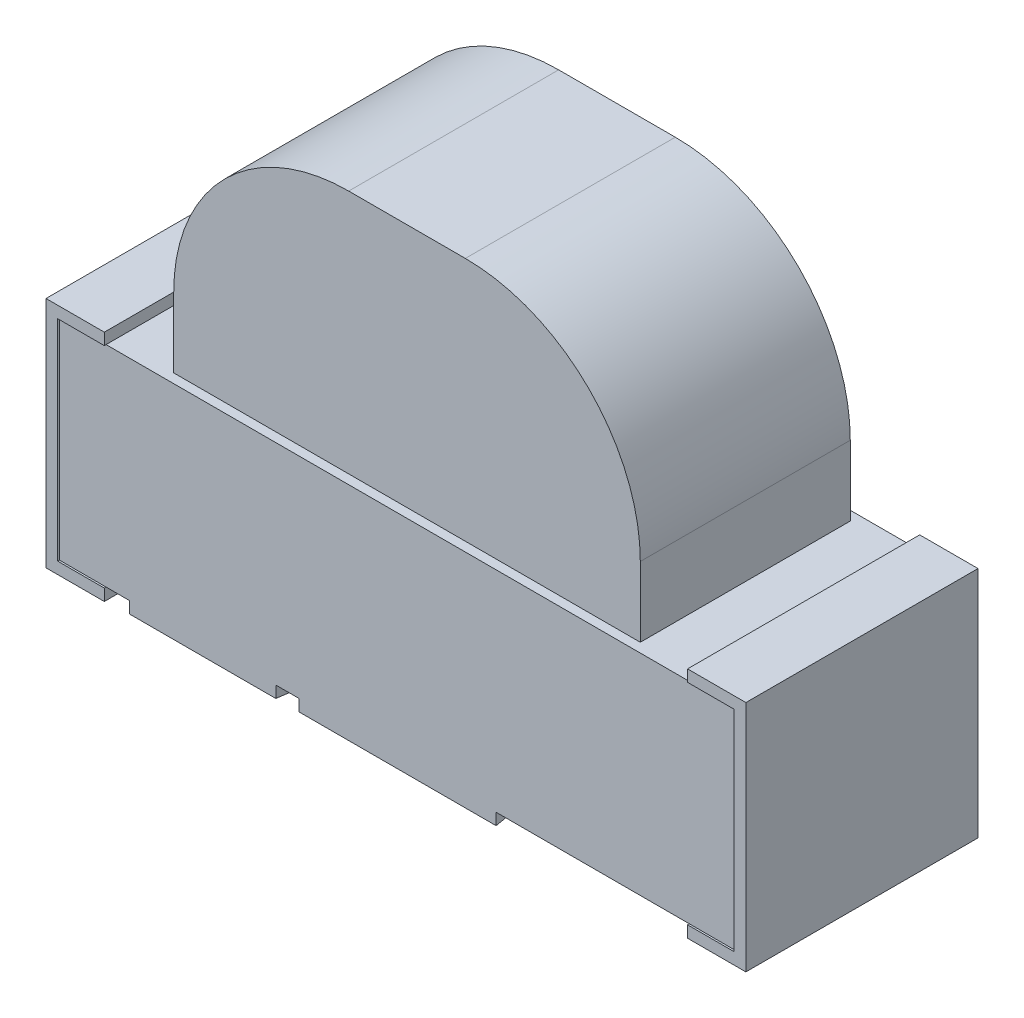
from build123d import *

# Parameters (mm, degrees)
SKIZZE1_W                       = 2.9
SKIZZE1_H                       = 0.98
LINEAR_AUSTRAGEN1_DEPTH         = 0.9
LINEAR_AUSTRAGEN2_DEPTH         = 0.45
SKIZZE5_W                       = 3
SKIZZE5_H                       = 1.08
SKIZZE5_W_2                     = 2.9
SKIZZE5_H_2                     = 0.98
LINEAR_AUSTRAGEN6_DEPTH         = 0.9
SKIZZE6_W                       = 0.25
SKIZZE6_H                       = 1.08
LINEAR_AUSTRAGEN7_DEPTH         = 0.05
SKIZZE7_W                       = 0.25
SKIZZE7_H                       = 1.08
LINEAR_AUSTRAGEN8_DEPTH         = 0.05
LINEAR_AUSTRAGEN9_DEPTH         = 0.05
SCHNITT_LINEAR_AUSTRAGEN2_DEPTH = 0.05
SKIZZE10_W                      = 3
SKIZZE10_H                      = 1
SCHNITT_LINEAR_AUSTRAGEN3_DEPTH = 0.0425


with BuildPart() as part:
    # Skizze1 → Linear austragen1 (new body)
    with BuildSketch(Plane(origin=(0, 0, 0), x_dir=(1, 0, 0), z_dir=(0, 1, 0))):
        Rectangle(SKIZZE1_W, SKIZZE1_H)
    extrude(amount=LINEAR_AUSTRAGEN1_DEPTH)



with BuildPart() as body_2:
    # Skizze2 → Linear austragen2 (new body, symmetric)
    with BuildSketch(Plane.XY):
        with BuildLine():
            Line((-1, 0.9), (1, 0.9))
            Line((1, 0.9), (1, 1.2))
            ThreePointArc((1, 1.2), (0.780330086, 1.730330086), (0.25, 1.95))
            Line((0.25, 1.95), (-0.25, 1.95))
            ThreePointArc((-0.25, 1.95), (-0.780330086, 1.730330086), (-1, 1.2))
            Line((-1, 1.2), (-1, 0.9))
        make_face()
    extrude(amount=LINEAR_AUSTRAGEN2_DEPTH, both=True)


with BuildPart() as body_3:
    # Skizze5 → Linear austragen6 (new body)
    with BuildSketch(Plane(origin=(0, 0.9, 0), x_dir=(1, 0, 0), z_dir=(0, 1, 0))):
        Rectangle(SKIZZE5_W, SKIZZE5_H)
        Rectangle(SKIZZE5_W_2, SKIZZE5_H_2, mode=Mode.SUBTRACT)
    extrude(amount=-LINEAR_AUSTRAGEN6_DEPTH)


with BuildPart() as part_1:
    add(part.part)

    add(body_3.part)  # Linear austragen7 merges body 3
    # Skizze6 → Linear austragen7 (add)
    with BuildSketch(Plane(origin=(0, 0.9, 0), x_dir=(1, 0, 0), z_dir=(0, 1, 0))):
        with Locations((1.375, 0)):
            Rectangle(SKIZZE6_W, SKIZZE6_H)
        with Locations((-1.375, 0)):
            Rectangle(SKIZZE6_W, SKIZZE6_H)
    extrude(amount=LINEAR_AUSTRAGEN7_DEPTH)

    # Skizze7 → Linear austragen8 (add)
    with BuildSketch(Plane.XZ):
        with Locations((1.375, 0)):
            Rectangle(SKIZZE7_W, SKIZZE7_H)
        with Locations((-1.375, 0)):
            Rectangle(SKIZZE7_W, SKIZZE7_H)
    extrude(amount=LINEAR_AUSTRAGEN8_DEPTH)

    # Skizze8 → Linear austragen9 (add)
    with BuildSketch(Plane.XZ):
        with BuildLine():
            Line((-0.125, 0.13379808), (-0.125, -0.13379808))
            ThreePointArc((-0.125, -0.13379808), (-0.341869858, -0.287512377), (-0.425, -0.54))
            Line((-0.425, -0.54), (0.425, -0.54))
            ThreePointArc((0.425, -0.54), (0.341869858, -0.287512377), (0.125, -0.13379808))
            Line((0.125, -0.13379808), (0.125, 0.13379808))
            ThreePointArc((0.125, 0.13379808), (0.341869858, 0.287512377), (0.425, 0.54))
            Line((0.425, 0.54), (-0.425, 0.54))
            ThreePointArc((-0.425, 0.54), (-0.341869858, 0.287512377), (-0.125, 0.13379808))
        make_face()
        with BuildLine():
            Line((-0.225, 0.065658351), (-0.225, -0.065658351))
            ThreePointArc((-0.225, -0.065658351), (-0.443705984, -0.259375696), (-0.525, -0.54))
            Line((-0.525, -0.54), (-1.15, -0.54))
            Line((-1.15, -0.54), (-1.15, 0.54))
            Line((-1.15, 0.54), (-0.525, 0.54))
            ThreePointArc((-0.525, 0.54), (-0.443705984, 0.259375696), (-0.225, 0.065658351))
        make_face()
    extrude(amount=LINEAR_AUSTRAGEN9_DEPTH)

    # Skizze9 → Schnitt-Linear austragen2 (cut)
    with BuildSketch(Plane.XY.offset(0.54)):
        Polygon((-1.45, 0.9), (-1.45, 0), (-1.25, 0), (-1.25, -0.05), (1.25, -0.05), (1.25, 0), (1.449568933, 0), (1.449568933, 0.9), align=None)
    schnitt_linear_austragen2 = extrude(amount=-SCHNITT_LINEAR_AUSTRAGEN2_DEPTH, mode=Mode.SUBTRACT)

    # Spiegeln1: Schnitt-Linear austragen2 across plane
    add(schnitt_linear_austragen2.mirror(Plane.XY), mode=Mode.SUBTRACT)

    # Skizze10 → Schnitt-Linear austragen3 (cut)
    with BuildSketch(Plane.XY.offset(0.54)):
        with Locations((0, 0.45)):
            Rectangle(SKIZZE10_W, SKIZZE10_H)
    schnitt_linear_austragen3 = extrude(amount=-SCHNITT_LINEAR_AUSTRAGEN3_DEPTH, mode=Mode.SUBTRACT)

    # Spiegeln2: Schnitt-Linear austragen3 across plane
    add(schnitt_linear_austragen3.mirror(Plane.XY), mode=Mode.SUBTRACT)


solid = Compound([body_2.part, part_1.part])
